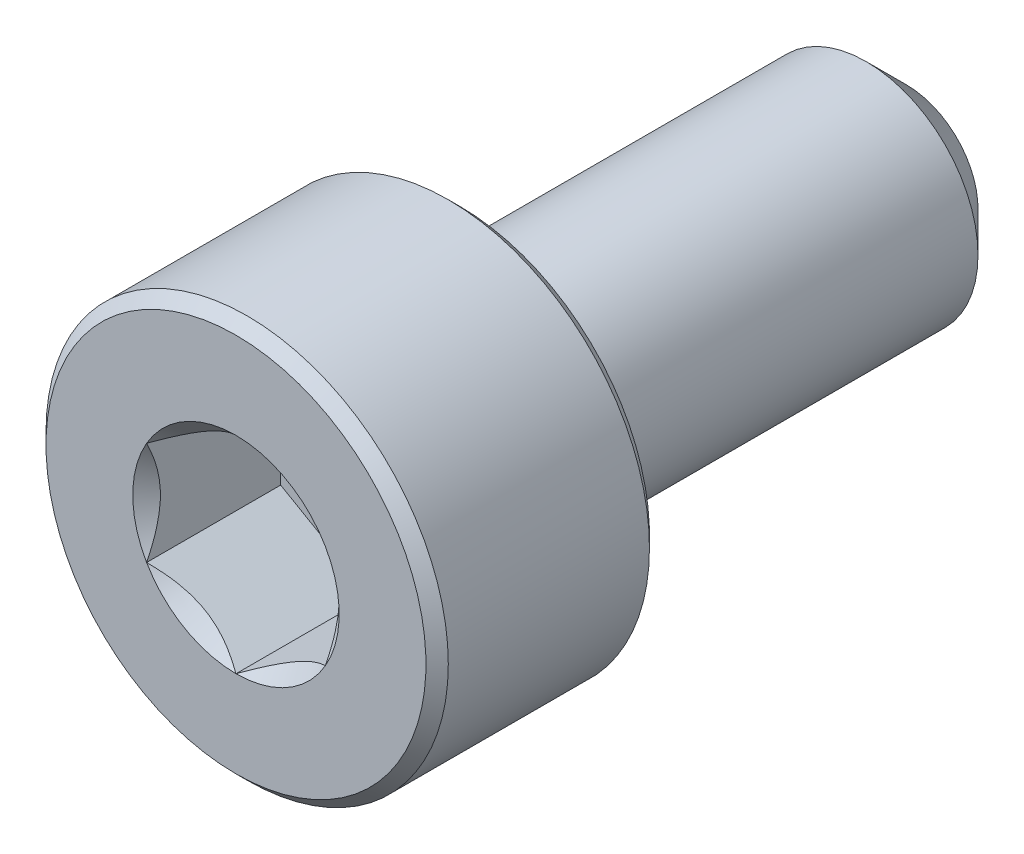
from build123d import *

# Parameters (mm, degrees)
CUT_EXTRUDE1_DEPTH = 1.5
SKETCH4_R          = 1.154700538
CUT_EXTRUDE2_DEPTH = 1.5
CUT_EXTRUDE2_DRAFT = -45


with BuildPart() as part:
    # Sketch2 → Revolve1 (revolve)
    with BuildSketch(Plane(origin=(0, 0, 0), x_dir=(0, 0, -1), z_dir=(1, 0, 0))):
        Polygon((-3.75, 0), (-3.75, 2.125), (-3.625, 2.25), (-1.375, 2.25), (-1.25, 2.125), (-1.25, 1.25), (3.3, 1.25), (3.75, 0.8), (3.75, 0), align=None)
    revolve(axis=Axis((0, 0, -3.75), (0, 0, 1)))

    # Sketch3 → Cut-Extrude1 (cut)
    with BuildSketch(Plane.XY.offset(3.75)):
        Polygon((1, -0.577350269), (1, 0.577350269), (0, 1.154700538), (-1, 0.577350269), (-1, -0.577350269), (0, -1.154700538), align=None)
    extrude(amount=-CUT_EXTRUDE1_DEPTH, mode=Mode.SUBTRACT)


with BuildPart() as cut_extrude2_tool:
    # Sketch4 → Cut-Extrude2 (with draft: the straight prism first)
    with BuildSketch(Plane.XY.offset(3.75)):
        Circle(SKETCH4_R)
    extrude(amount=-CUT_EXTRUDE2_DEPTH)
    # Cut-Extrude2: the draft: its side faces are tilted about the plane it starts from
    cut_extrude2_sides = [cut_extrude2_tool.faces().sort_by_distance(p)[0] for p in [
        (-1.154700538, 0, 3),
    ]]
    draft(cut_extrude2_sides, Plane.XY.offset(3.75), CUT_EXTRUDE2_DRAFT)


with BuildPart() as part_1:
    add(part.part)

    # Cut-Extrude2: cut by cut_extrude2_tool
    add(cut_extrude2_tool.part, mode=Mode.SUBTRACT)


solid = part_1.part
